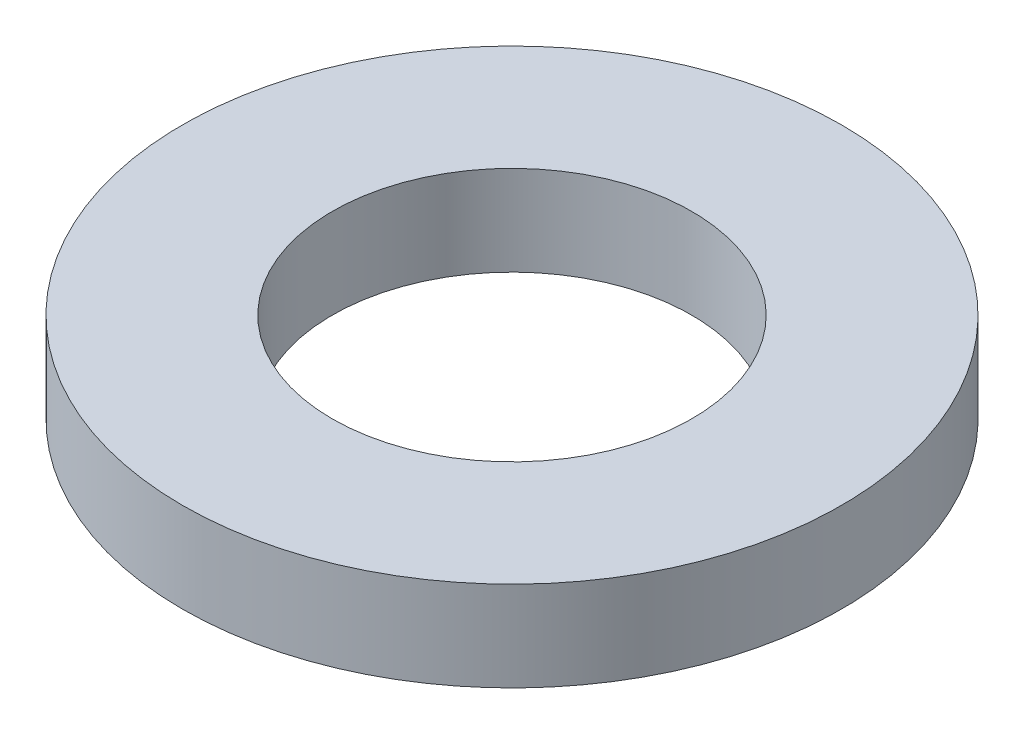
from build123d import *

# Parameters (mm, degrees)
SKETCH_1_R      = 11
SKETCH_1_R_2    = 6
EXTRUDE_1_DEPTH = 3


with BuildPart() as part:
    # 草图1 → 凸台-拉伸1 (new body)
    with BuildSketch(Plane(origin=(0, 0, 0), x_dir=(1, 0, 0), z_dir=(0, 1, 0))):
        Circle(SKETCH_1_R)
        Circle(SKETCH_1_R_2, mode=Mode.SUBTRACT)
    extrude(amount=EXTRUDE_1_DEPTH)


solid = part.part
